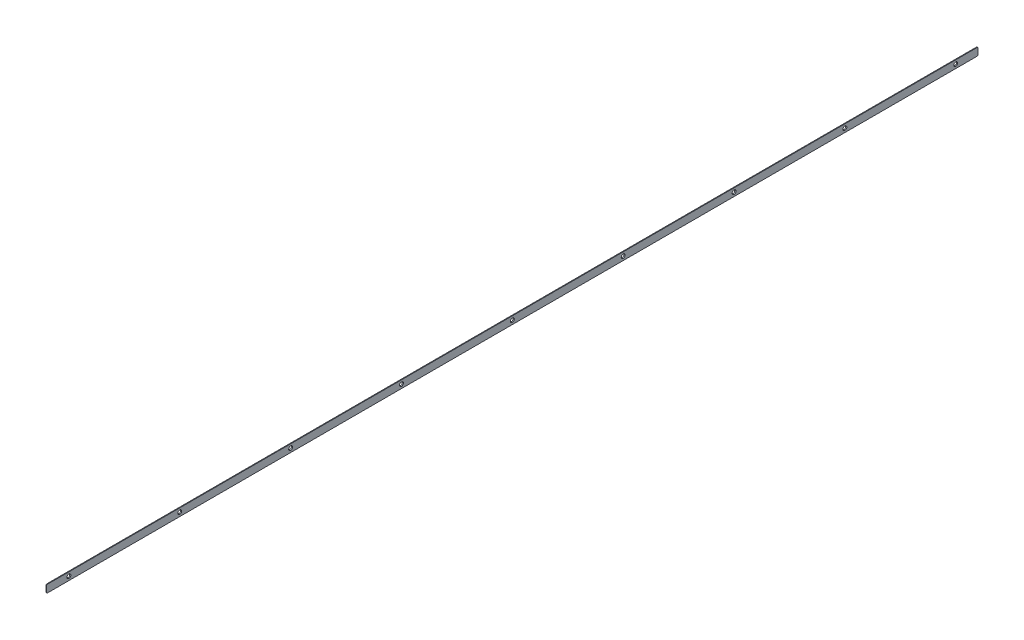
from build123d import *

# Parameters (mm, degrees)
SKETCH1_W           = 1046
SKETCH1_H           = 8.541
BOSS_EXTRUDE1_DEPTH = 0.762
LPATTERN1_COUNT     = 9
LPATTERN1_PITCH     = 124.5
FILLET2_R           = 1


with BuildPart() as part:
    # Sketch1 → Boss-Extrude1 (new body)
    with BuildSketch(Plane(origin=(0, 0, 0), x_dir=(0, 0, -1), z_dir=(1, 0, 0))):
        Rectangle(SKETCH1_W, SKETCH1_H)
    extrude(amount=BOSS_EXTRUDE1_DEPTH)

    # Sketch2 → CSK for #2 Flat Head Machine Screw1 (revolve, cut)
    with BuildSketch(Plane(origin=(0.762, 0, 498), x_dir=(0, 0, -1), z_dir=(0, 1, 0))):
        Polygon((0, 0), (0, 0.762), (1.2192, 0.762), (1.2192, 1.110335587), (2.1844, 0), align=None)
    csk_for_2_flat_head_machine_screw1 = revolve(axis=Axis((7.112, 0, 498), (-1, 0, 0)), mode=Mode.SUBTRACT)

    # LPattern1: CSK for #2 Flat Head Machine Screw1 ×9
    with Locations(*[(0, 0, -i * LPATTERN1_PITCH) for i in range(1, LPATTERN1_COUNT)]):
        add(csk_for_2_flat_head_machine_screw1, mode=Mode.SUBTRACT)

    # Fillet2
    fillet2_edges = [part.edges().sort_by_distance(p)[0] for p in [
        (0.381, -4.2705, -523),
        (0.381, -4.2705, 523),
        (0.381, 4.2705, 523),
        (0.381, 4.2705, -523),
    ]]
    fillet(fillet2_edges, radius=FILLET2_R)


solid = part.part
